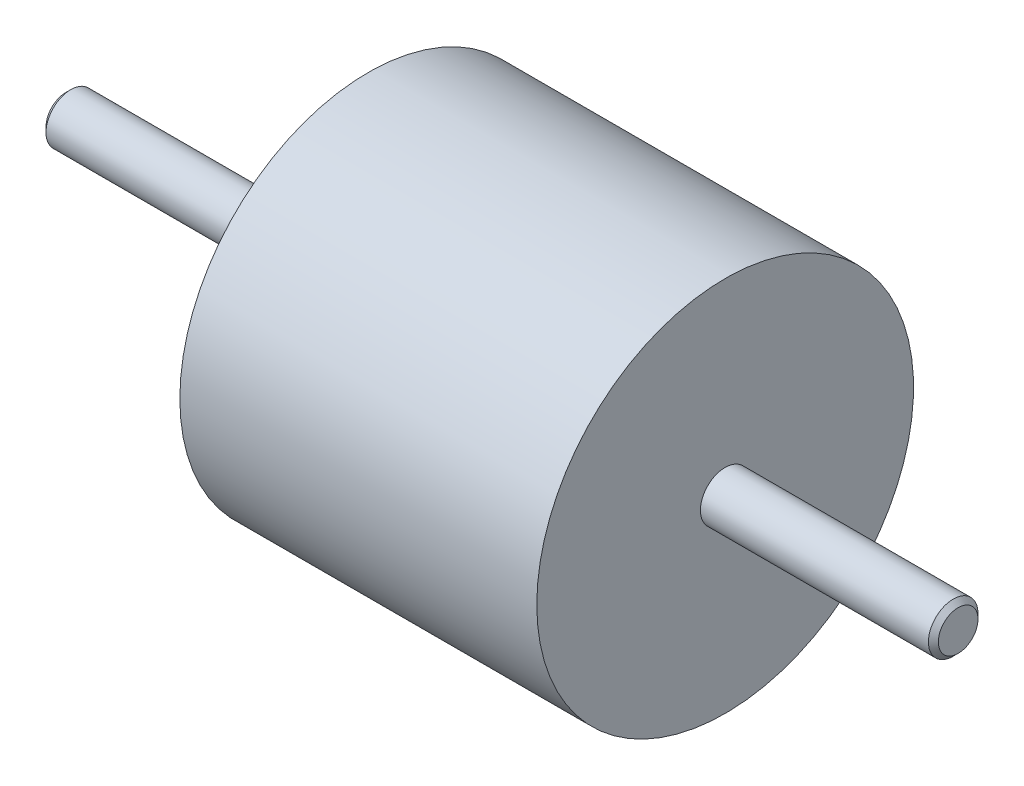
from build123d import *

# Parameters (mm, degrees)
CHANFREIN1_SIZE = 0.5


with BuildPart() as part:
    # Esquisse1 → Révolution1 (revolve)
    with BuildSketch(Plane.XY, mode=Mode.PRIVATE) as r_volution1_sk:
        Polygon((-33.336541, -19.392259), (2.663459, -19.392259), (2.663459, -35.892259), (26.163459, -35.892259), (26.163459, -38.392259), (-63.836541, -38.392259), (-63.836541, -35.892259), (-33.336541, -35.892259), align=None)
    revolve(r_volution1_sk.sketch.rotate(Axis((-107.151340206, -38.392259, 0), (1, 0, 0)), 90), axis=Axis((-107.151340206, -38.392259, 0), (1, 0, 0)))  # turned: the seam where the file's is

    # Chanfrein1
    chanfrein1_edges = [part.edges().sort_by_distance(p)[0] for p in [
        (26.163459, -38.392259, -2.5),
        (-63.836541, -38.392259, -2.5),
    ]]
    chamfer(chanfrein1_edges, length=CHANFREIN1_SIZE)


solid = part.part
